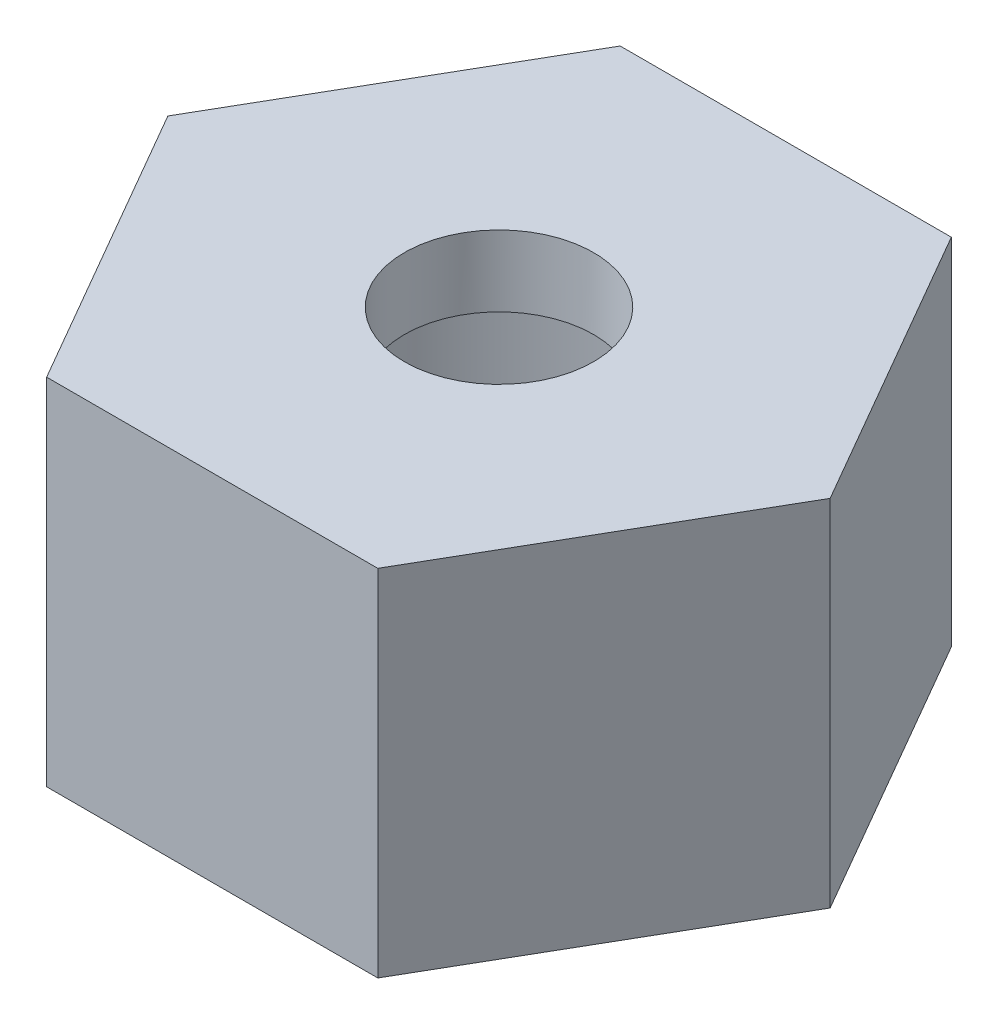
from build123d import *

# Parameters (mm, degrees)
BOSS_EXTRUDE1_DEPTH = 7.5
SKETCH2_R           = 10
CUT_EXTRUDE2_DEPTH  = 12
SKETCH3_R           = 4
CUT_EXTRUDE3_DEPTH  = 16


with BuildPart() as part:
    # Sketch1 → Boss-Extrude1 (new body, symmetric)
    with BuildSketch(Plane(origin=(0, 0, 0), x_dir=(1, 0, 0), z_dir=(0, 1, 0))):
        Polygon((-14, 0), (-7, -12.124355653), (7, -12.124355653), (14, 0), (7, 12.124355653), (-7, 12.124355653), align=None)
    extrude(amount=BOSS_EXTRUDE1_DEPTH, both=True)

    # Sketch2 → Cut-Extrude2 (cut)
    with BuildSketch(Plane.XZ.offset(7.5)):
        Circle(SKETCH2_R)
    extrude(amount=-CUT_EXTRUDE2_DEPTH, mode=Mode.SUBTRACT)

    # Sketch3 → Cut-Extrude3 (cut, through all)
    with BuildSketch(Plane(origin=(0, 7.5, 0), x_dir=(1, 0, 0), z_dir=(0, 1, 0))):
        Circle(SKETCH3_R)
    extrude(amount=-CUT_EXTRUDE3_DEPTH, mode=Mode.SUBTRACT)


solid = part.part
